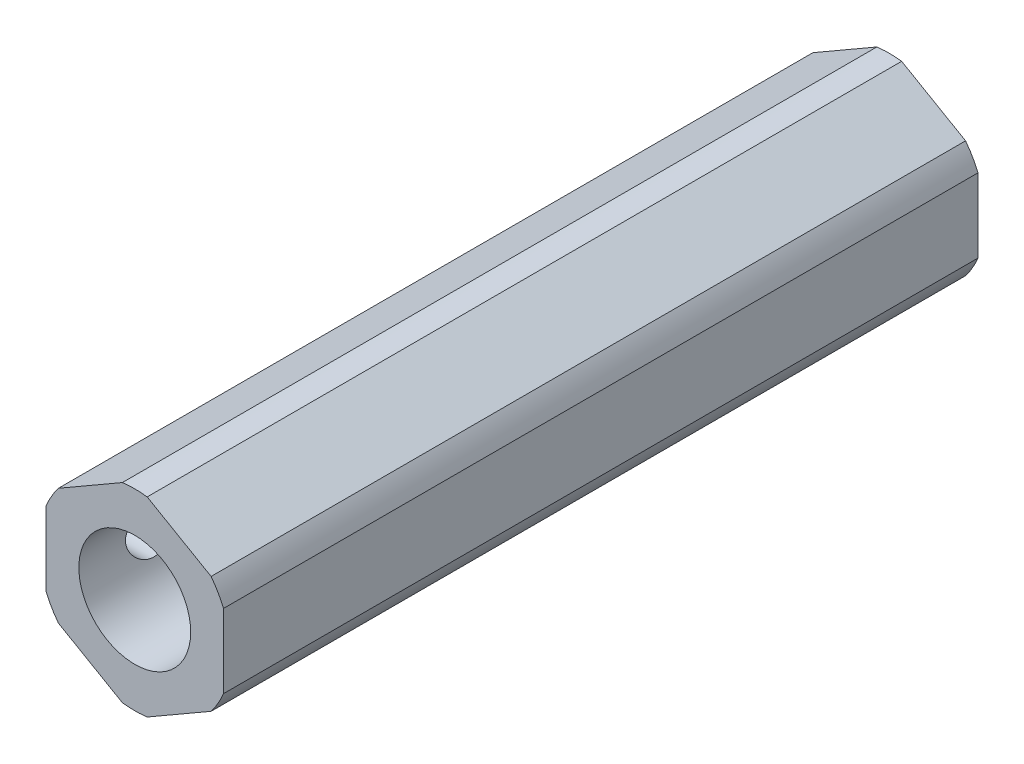
from build123d import *

# Parameters (mm, degrees)
SKETCH1_R               = 6.35
BASIC_ROD_DEPTH         = 26.9875
BASIC_ROD_DEPTH_BACK    = 26.9875
THEX_DEPTH              = 26.9875
SKETCH2_R               = 2.11582
INTERNAL_CUT_DEPTH      = 27.9875
INTERNAL_CUT_DEPTH_BACK = 27.9875
SKETCH9_R               = 4
CUT_EXTRUDE1_DEPTH      = 19.99996
CUT_EXTRUDE2_REACH      = 14.7
SKETCH10_R              = 1.66624


with BuildPart() as part:
    # Sketch1 → Basic Rod (new body, two sides)
    with BuildSketch(Plane.XY) as basic_rod_sk:
        Circle(SKETCH1_R)
    extrude(amount=BASIC_ROD_DEPTH)
    extrude(basic_rod_sk.sketch, amount=-BASIC_ROD_DEPTH_BACK)

    # Sketch8 → THex (add, symmetric)
    with BuildSketch(Plane.XY):
        with BuildLine():
            Line((-0.888411378, 6.819423871), (-5.461588622, 4.179098758))
            ThreePointArc((-5.461588622, 4.179098758), (-5.955700003, 3.438525), (-6.35, 2.640325113))
            Line((-6.35, 2.640325113), (-6.35, -2.640325113))
            ThreePointArc((-6.35, -2.640325113), (-5.955700003, -3.438525), (-5.461588622, -4.179098758))
            Line((-5.461588622, -4.179098758), (-0.888411378, -6.819423871))
            ThreePointArc((-0.888411378, -6.819423871), (0, -6.87705), (0.888411378, -6.819423871))
            Line((0.888411378, -6.819423871), (5.461588622, -4.179098758))
            ThreePointArc((5.461588622, -4.179098758), (5.955700003, -3.438525), (6.35, -2.640325113))
            Line((6.35, -2.640325113), (6.35, 2.640325113))
            ThreePointArc((6.35, 2.640325113), (5.955700003, 3.438525), (5.461588622, 4.179098758))
            Line((5.461588622, 4.179098758), (0.888411378, 6.819423871))
            ThreePointArc((0.888411378, 6.819423871), (0, 6.87705), (-0.888411378, 6.819423871))
        make_face()
    extrude(amount=THEX_DEPTH, both=True)

    # Sketch2 → Internal Cut (cut, two sides)
    with BuildSketch(Plane.XY) as internal_cut_sk:
        Circle(SKETCH2_R)
    extrude(amount=INTERNAL_CUT_DEPTH, mode=Mode.SUBTRACT)
    extrude(internal_cut_sk.sketch, amount=-INTERNAL_CUT_DEPTH_BACK, mode=Mode.SUBTRACT)

    # Sketch9 → Cut-Extrude1 (cut)
    with BuildSketch(Plane.XY.offset(26.9875)):
        Circle(SKETCH9_R)
    extrude(amount=-CUT_EXTRUDE1_DEPTH, mode=Mode.SUBTRACT)

    # Sketch10 → Cut-Extrude2 (cut, up to next)
    with BuildSketch(Plane.ZY.offset(6.35), mode=Mode.PRIVATE) as cut_extrude2_sk1:
        with Locations((13.98524, 0)):
            Circle(SKETCH10_R)
    cut_extrude2_tool1 = extrude(cut_extrude2_sk1.sketch, amount=-CUT_EXTRUDE2_REACH, mode=Mode.PRIVATE) & part.part
    add(cut_extrude2_tool1.solids().sort_by_distance((-6.35, 0, 13.98524))[0], mode=Mode.SUBTRACT)
    # Sketch10 → Cut-Extrude2 (cut, up to next)
    with BuildSketch(Plane.ZY.offset(6.35), mode=Mode.PRIVATE) as cut_extrude2_sk2:
        with Locations((21.98624, 0)):
            Circle(SKETCH10_R)
    cut_extrude2_tool2 = extrude(cut_extrude2_sk2.sketch, amount=-CUT_EXTRUDE2_REACH, mode=Mode.PRIVATE) & part.part
    add(cut_extrude2_tool2.solids().sort_by_distance((-6.35, 0, 21.98624))[0], mode=Mode.SUBTRACT)


solid = part.part
